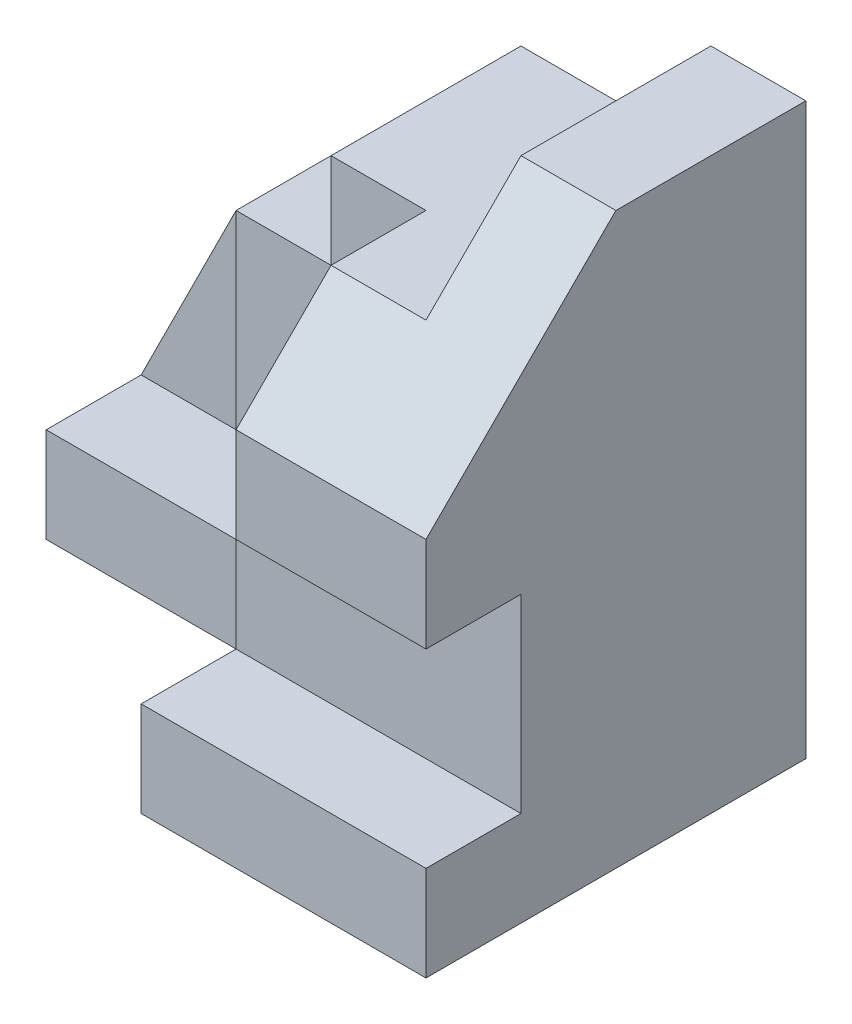
from build123d import *

# Parameters (mm, degrees)
BOSS_EXTRUDE1_DEPTH = 60
CUT_EXTRUDE1_DEPTH  = 41
SKETCH3_W           = 20
SKETCH3_H           = 20
CUT_EXTRUDE2_DEPTH  = 10
CHAMFER1_SIZE       = 20
SKETCH4_W           = 10
SKETCH4_H           = 20
CUT_EXTRUDE3_DEPTH  = 30
SKETCH5_W           = 10
SKETCH5_H           = 20
CUT_EXTRUDE4_DEPTH  = 30


with BuildPart() as part:
    # Sketch1 → Boss-Extrude1 (new body)
    with BuildSketch(Plane(origin=(0, 0, 0), x_dir=(1, 0, 0), z_dir=(0, 1, 0))):
        Polygon((0, 0), (60, 0), (60, -40), (30, -40), (30, -20), (0, -20), align=None)
    extrude(amount=BOSS_EXTRUDE1_DEPTH)

    # Sketch2 → Cut-Extrude1 (cut, through all)
    with BuildSketch(Plane.XY.offset(40)):
        Polygon((50, 60), (50, 50), (30, 50), (30, 40), (20, 40), (20, 30), (10, 30), (0, 10), (0, 60), align=None)
    extrude(amount=-CUT_EXTRUDE1_DEPTH, mode=Mode.SUBTRACT)

    # Sketch3 → Cut-Extrude2 (cut)
    with BuildSketch(Plane.XY.offset(20)):
        with Locations((10, 20)):
            Rectangle(SKETCH3_W, SKETCH3_H)
    extrude(amount=-CUT_EXTRUDE2_DEPTH, mode=Mode.SUBTRACT)

    # Chamfer1
    chamfer1_edges = [part.edges().sort_by_distance(p)[0] for p in [
        (55, 60, 40),
    ]]
    chamfer(chamfer1_edges, length=CHAMFER1_SIZE)

    # Sketch4 → Cut-Extrude3 (cut)
    with BuildSketch(Plane(origin=(0, 50, 0), x_dir=(1, 0, 0), z_dir=(0, 1, 0))):
        with Locations((35, -30)):
            Rectangle(SKETCH4_W, SKETCH4_H)
    extrude(amount=-CUT_EXTRUDE3_DEPTH, mode=Mode.SUBTRACT)

    # Sketch5 → Cut-Extrude4 (cut)
    with BuildSketch(Plane.ZY.offset(-30)):
        with Locations((35, 20)):
            Rectangle(SKETCH5_W, SKETCH5_H)
    extrude(amount=-CUT_EXTRUDE4_DEPTH, mode=Mode.SUBTRACT)


solid = part.part
